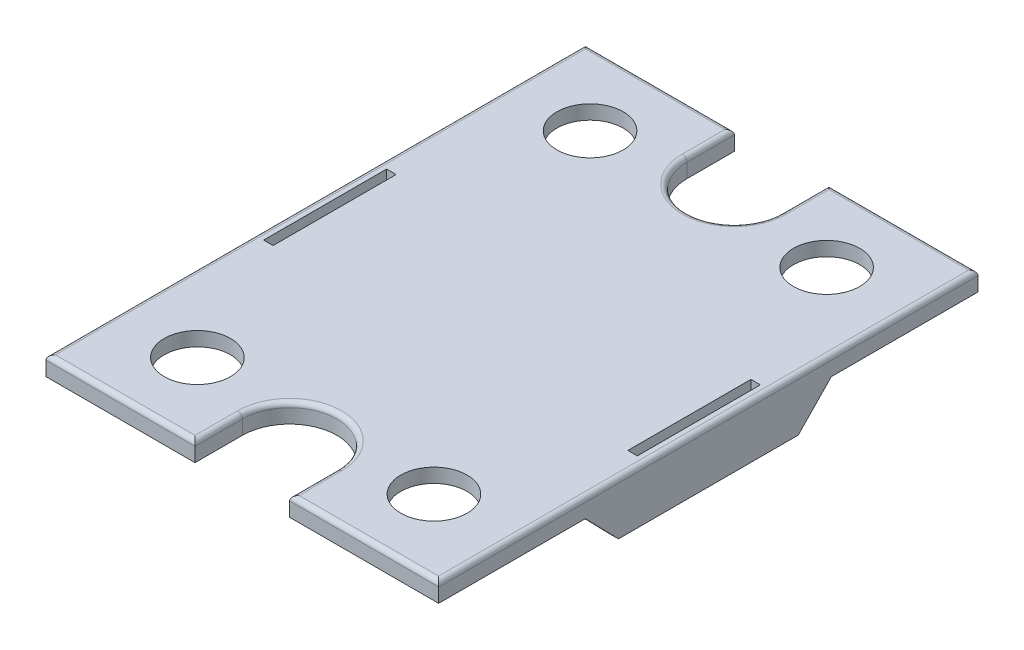
from build123d import *

# Parameters (mm, degrees)
SKETCH1_W           = 41.5
SKETCH1_H           = 57
BOSS_EXTRUDE1_DEPTH = 2
CUT_EXTRUDE1_DEPTH  = 3
SKETCH3_R           = 3.5
CUT_EXTRUDE2_DEPTH  = 3
SKETCH4_W           = 2
SKETCH4_H           = 13
CUT_EXTRUDE3_DEPTH  = 3
CUT_EXTRUDE4_DEPTH  = 0.5
BOSS_EXTRUDE2_DEPTH = 1
SKETCH7_W           = 3.5
SKETCH7_H           = 0.6
BOSS_EXTRUDE3_DEPTH = 0.3
FILLET1_R           = 0.5


with BuildPart() as part:
    # Sketch1 → Boss-Extrude1 (new body)
    with BuildSketch(Plane(origin=(0, 0, 0), x_dir=(1, 0, 0), z_dir=(0, 1, 0))):
        Rectangle(SKETCH1_W, SKETCH1_H)
    extrude(amount=BOSS_EXTRUDE1_DEPTH)

    # Sketch2 → Cut-Extrude1 (cut, through all)
    with BuildSketch(Plane(origin=(0, 2, 0), x_dir=(1, 0, 0), z_dir=(0, 1, 0))):
        with BuildLine():
            Line((-5, -23.5), (-5, -28.5))
            Line((-5, -28.5), (5, -28.5))
            Line((5, -28.5), (5, -23.5))
            ThreePointArc((5, -23.5), (0, -18.5), (-5, -23.5))
        make_face()
    cut_extrude1 = extrude(amount=-CUT_EXTRUDE1_DEPTH, mode=Mode.SUBTRACT)

    # Sketch3 → Cut-Extrude2 (cut, through all)
    with BuildSketch(Plane(origin=(0, 2, 0), x_dir=(1, 0, 0), z_dir=(0, 1, 0))):
        with Locations((-12.5, -20.75)):
            Circle(SKETCH3_R)
        with Locations((12.5, -20.75)):
            Circle(SKETCH3_R)
    cut_extrude2 = extrude(amount=-CUT_EXTRUDE2_DEPTH, mode=Mode.SUBTRACT)

    # Mirror1: Cut-Extrude1, Cut-Extrude2 across plane
    add(cut_extrude1.mirror(Plane.XY), mode=Mode.SUBTRACT)
    add(cut_extrude2.mirror(Plane.XY), mode=Mode.SUBTRACT)

    # Sketch4 → Cut-Extrude3 (cut, through all)
    with BuildSketch(Plane(origin=(0, 2, 0), x_dir=(1, 0, 0), z_dir=(0, 1, 0))):
        with Locations((-19.75, 0)):
            Rectangle(SKETCH4_W, SKETCH4_H)
        with Locations((19.75, 0)):
            Rectangle(SKETCH4_W, SKETCH4_H)
    extrude(amount=-CUT_EXTRUDE3_DEPTH, mode=Mode.SUBTRACT)

    # Sketch5 → Cut-Extrude4 (cut)
    with BuildSketch(Plane(origin=(0, 0, 0), x_dir=(1, 0, 0), z_dir=(0, 1, 0))):
        with BuildLine():
            Line((-18.75, 26.5), (-18.75, 8.5))
            Line((-18.75, 8.5), (-16.75, 8.5))
            Line((-16.75, 8.5), (-16.75, -8.5))
            Line((-16.75, -8.5), (-18.75, -8.5))
            Line((-18.75, -8.5), (-18.75, -26.5))
            Line((-18.75, -26.5), (-7, -26.5))
            Line((-7, -26.5), (-7, -23.5))
            ThreePointArc((-7, -23.5), (0, -16.5), (7, -23.5))
            Line((7, -23.5), (7, -26.5))
            Line((7, -26.5), (18.75, -26.5))
            Line((18.75, -26.5), (18.75, -8.5))
            Line((18.75, -8.5), (16.75, -8.5))
            Line((16.75, -8.5), (16.75, 8.5))
            Line((16.75, 8.5), (18.75, 8.5))
            Line((18.75, 8.5), (18.75, 26.5))
            Line((18.75, 26.5), (7, 26.5))
            Line((7, 26.5), (7, 23.5))
            ThreePointArc((7, 23.5), (0, 16.5), (-7, 23.5))
            Line((-7, 23.5), (-7, 26.5))
            Line((-7, 26.5), (-18.75, 26.5))
        make_face()
    extrude(amount=CUT_EXTRUDE4_DEPTH, mode=Mode.SUBTRACT)

    # Sketch6 → Boss-Extrude2 (add)
    with BuildSketch(Plane.ZY.offset(20.75)):
        Polygon((-13, 2), (13, 2), (13, 0), (9.5, -3.6), (-9.5, -3.6), (-13, 0), align=None)
    boss_extrude2 = extrude(amount=-BOSS_EXTRUDE2_DEPTH)

    # Sketch7 → Boss-Extrude3 (add)
    with BuildSketch(Plane(origin=(-19.75, 0, 0), x_dir=(0, 0, -1), z_dir=(1, 0, 0))):
        with Locations((-4.75, -3.3)):
            Rectangle(SKETCH7_W, SKETCH7_H)
        with Locations((4.75, -3.3)):
            Rectangle(SKETCH7_W, SKETCH7_H)
    boss_extrude3 = extrude(amount=BOSS_EXTRUDE3_DEPTH)

    # Mirror2: Boss-Extrude2, Boss-Extrude3 across plane
    add(boss_extrude2.mirror(Plane(origin=(0, 0, 0), x_dir=(0, 0, 1), z_dir=(1, 0, 0))))
    add(boss_extrude3.mirror(Plane(origin=(0, 0, 0), x_dir=(0, 0, 1), z_dir=(1, 0, 0))))

    # Fillet1
    fillet1_edges = [part.edges().sort_by_distance(p)[0] for p in [
        (-20.75, 2, 0),
        (-12.875, 2, 28.5),
        (12.875, 2, 28.5),
        (5, 2, 26),
        (0, 2, 18.5),
        (-5, 2, 26),
        (20.75, 2, 0),
        (-12.875, 2, -28.5),
        (5, 2, -26),
        (0, 2, -18.5),
        (-5, 2, -26),
        (12.875, 2, -28.5),
    ]]
    fillet(fillet1_edges, radius=FILLET1_R)


solid = part.part
